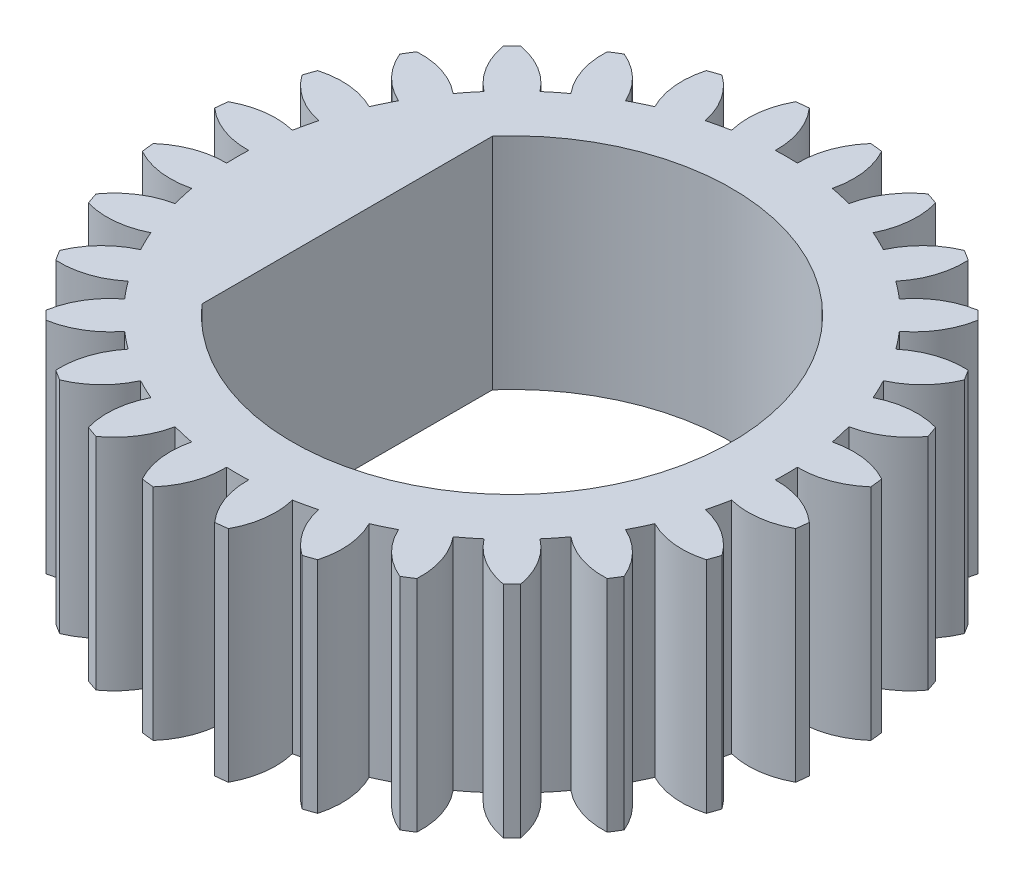
from build123d import *

# Parameters (mm, degrees)
BOSS_EXTRUDE1_DEPTH = 1
SCALE1_SCALE        = 2


with BuildPart() as part:
    # Sketch1 → Boss-Extrude1 (new body)
    with BuildSketch(Plane(origin=(0, 0, 0), x_dir=(1, 0, 0), z_dir=(0, 1, 0))):
        with BuildLine():
            ThreePointArc((0.19583451, 1.487161338), (0.167946714, 1.490568315), (0.14, 1.493452376))
            ThreePointArc((0.14, 1.493452376), (0.071938149, 1.379716653), (0.05, 1.2489996))
            ThreePointArc((0.05, 1.2489996), (0, 1.25), (-0.05, 1.2489996))
            ThreePointArc((-0.05, 1.2489996), (-0.071938149, 1.379716653), (-0.14, 1.493452376))
            ThreePointArc((-0.14, 1.493452376), (-0.167946714, 1.490568315), (-0.19583451, 1.487161338))
            ThreePointArc((-0.19583451, 1.487161338), (-0.236881329, 1.36113202), (-0.229182162, 1.228810619))
            ThreePointArc((-0.229182162, 1.228810619), (-0.278151167, 1.21865989), (-0.326674953, 1.206558525))
            ThreePointArc((-0.326674953, 1.206558525), (-0.377150347, 1.329116532), (-0.468814325, 1.424855476))
            ThreePointArc((-0.468814325, 1.424855476), (-0.495418593, 1.415824995), (-0.52184906, 1.40629782))
            ThreePointArc((-0.52184906, 1.40629782), (-0.533822588, 1.274294544), (-0.496872173, 1.147003942))
            ThreePointArc((-0.496872173, 1.147003942), (-0.542354674, 1.126211085), (-0.58696906, 1.103615568))
            ThreePointArc((-0.58696906, 1.103615568), (-0.663450653, 1.211868958), (-0.774120343, 1.284810373))
            ThreePointArc((-0.774120343, 1.284810373), (-0.798048115, 1.270086299), (-0.821695919, 1.254916658))
            ThreePointArc((-0.821695919, 1.254916658), (-0.803995753, 1.123558618), (-0.739646939, 1.007681699))
            ThreePointArc((-0.739646939, 1.007681699), (-0.779362252, 0.977289353), (-0.817830087, 0.945332719))
            ThreePointArc((-0.817830087, 0.945332719), (-0.916482772, 1.033853214), (-1.040608734, 1.080339513))
            ThreePointArc((-1.040608734, 1.080339513), (-1.060660172, 1.060660172), (-1.080339513, 1.040608734))
            ThreePointArc((-1.080339513, 1.040608734), (-1.033853214, 0.916482772), (-0.945332719, 0.817830087))
            ThreePointArc((-0.945332719, 0.817830087), (-0.977289353, 0.779362252), (-1.007681699, 0.739646939))
            ThreePointArc((-1.007681699, 0.739646939), (-1.123558618, 0.803995753), (-1.254916658, 0.821695919))
            ThreePointArc((-1.254916658, 0.821695919), (-1.270086299, 0.798048115), (-1.284810373, 0.774120343))
            ThreePointArc((-1.284810373, 0.774120343), (-1.211868958, 0.663450653), (-1.103615568, 0.58696906))
            ThreePointArc((-1.103615568, 0.58696906), (-1.126211085, 0.542354674), (-1.147003942, 0.496872173))
            ThreePointArc((-1.147003942, 0.496872173), (-1.274294544, 0.533822588), (-1.40629782, 0.52184906))
            ThreePointArc((-1.40629782, 0.52184906), (-1.415824995, 0.495418593), (-1.424855476, 0.468814325))
            ThreePointArc((-1.424855476, 0.468814325), (-1.329116532, 0.377150347), (-1.206558525, 0.326674953))
            ThreePointArc((-1.206558525, 0.326674953), (-1.21865989, 0.278151167), (-1.228810619, 0.229182162))
            ThreePointArc((-1.228810619, 0.229182162), (-1.36113202, 0.236881329), (-1.487161338, 0.19583451))
            ThreePointArc((-1.487161338, 0.19583451), (-1.490568315, 0.167946714), (-1.493452376, 0.14))
            ThreePointArc((-1.493452376, 0.14), (-1.379716653, 0.071938149), (-1.2489996, 0.05))
            ThreePointArc((-1.2489996, 0.05), (-1.25, 0), (-1.2489996, -0.05))
            ThreePointArc((-1.2489996, -0.05), (-1.379716653, -0.071938149), (-1.493452376, -0.14))
            ThreePointArc((-1.493452376, -0.14), (-1.490568315, -0.167946714), (-1.487161338, -0.19583451))
            ThreePointArc((-1.487161338, -0.19583451), (-1.36113202, -0.236881329), (-1.228810619, -0.229182162))
            ThreePointArc((-1.228810619, -0.229182162), (-1.21865989, -0.278151167), (-1.206558525, -0.326674953))
            ThreePointArc((-1.206558525, -0.326674953), (-1.329116532, -0.377150347), (-1.424855476, -0.468814325))
            ThreePointArc((-1.424855476, -0.468814325), (-1.415824995, -0.495418593), (-1.40629782, -0.52184906))
            ThreePointArc((-1.40629782, -0.52184906), (-1.274294544, -0.533822588), (-1.147003942, -0.496872173))
            ThreePointArc((-1.147003942, -0.496872173), (-1.126211085, -0.542354674), (-1.103615568, -0.58696906))
            ThreePointArc((-1.103615568, -0.58696906), (-1.211868958, -0.663450653), (-1.284810373, -0.774120343))
            ThreePointArc((-1.284810373, -0.774120343), (-1.270086299, -0.798048115), (-1.254916658, -0.821695919))
            ThreePointArc((-1.254916658, -0.821695919), (-1.123558618, -0.803995753), (-1.007681699, -0.739646939))
            ThreePointArc((-1.007681699, -0.739646939), (-0.977289353, -0.779362252), (-0.945332719, -0.817830087))
            ThreePointArc((-0.945332719, -0.817830087), (-1.033853214, -0.916482772), (-1.080339513, -1.040608734))
            ThreePointArc((-1.080339513, -1.040608734), (-1.060660172, -1.060660172), (-1.040608734, -1.080339513))
            ThreePointArc((-1.040608734, -1.080339513), (-0.916482772, -1.033853214), (-0.817830087, -0.945332719))
            ThreePointArc((-0.817830087, -0.945332719), (-0.779362252, -0.977289353), (-0.739646939, -1.007681699))
            ThreePointArc((-0.739646939, -1.007681699), (-0.803995753, -1.123558618), (-0.821695919, -1.254916658))
            ThreePointArc((-0.821695919, -1.254916658), (-0.798048115, -1.270086299), (-0.774120343, -1.284810373))
            ThreePointArc((-0.774120343, -1.284810373), (-0.663450653, -1.211868958), (-0.58696906, -1.103615568))
            ThreePointArc((-0.58696906, -1.103615568), (-0.542354674, -1.126211085), (-0.496872173, -1.147003942))
            ThreePointArc((-0.496872173, -1.147003942), (-0.533822588, -1.274294544), (-0.52184906, -1.40629782))
            ThreePointArc((-0.52184906, -1.40629782), (-0.495418593, -1.415824995), (-0.468814325, -1.424855476))
            ThreePointArc((-0.468814325, -1.424855476), (-0.377150347, -1.329116532), (-0.326674953, -1.206558525))
            ThreePointArc((-0.326674953, -1.206558525), (-0.278151167, -1.21865989), (-0.229182162, -1.228810619))
            ThreePointArc((-0.229182162, -1.228810619), (-0.236881329, -1.36113202), (-0.19583451, -1.487161338))
            ThreePointArc((-0.19583451, -1.487161338), (-0.167946714, -1.490568315), (-0.14, -1.493452376))
            ThreePointArc((-0.14, -1.493452376), (-0.071938149, -1.379716653), (-0.05, -1.2489996))
            ThreePointArc((-0.05, -1.2489996), (0, -1.25), (0.05, -1.2489996))
            ThreePointArc((0.05, -1.2489996), (0.071938149, -1.379716653), (0.14, -1.493452376))
            ThreePointArc((0.14, -1.493452376), (0.167946714, -1.490568315), (0.19583451, -1.487161338))
            ThreePointArc((0.19583451, -1.487161338), (0.236881329, -1.36113202), (0.229182162, -1.228810619))
            ThreePointArc((0.229182162, -1.228810619), (0.278151167, -1.21865989), (0.326674953, -1.206558525))
            ThreePointArc((0.326674953, -1.206558525), (0.377150347, -1.329116532), (0.468814325, -1.424855476))
            ThreePointArc((0.468814325, -1.424855476), (0.495418593, -1.415824995), (0.52184906, -1.40629782))
            ThreePointArc((0.52184906, -1.40629782), (0.533822588, -1.274294544), (0.496872173, -1.147003942))
            ThreePointArc((0.496872173, -1.147003942), (0.542354674, -1.126211085), (0.58696906, -1.103615568))
            ThreePointArc((0.58696906, -1.103615568), (0.663450653, -1.211868958), (0.774120343, -1.284810373))
            ThreePointArc((0.774120343, -1.284810373), (0.798048115, -1.270086299), (0.821695919, -1.254916658))
            ThreePointArc((0.821695919, -1.254916658), (0.803995753, -1.123558618), (0.739646939, -1.007681699))
            ThreePointArc((0.739646939, -1.007681699), (0.779362252, -0.977289353), (0.817830087, -0.945332719))
            ThreePointArc((0.817830087, -0.945332719), (0.916482772, -1.033853214), (1.040608734, -1.080339513))
            ThreePointArc((1.040608734, -1.080339513), (1.060660172, -1.060660172), (1.080339513, -1.040608734))
            ThreePointArc((1.080339513, -1.040608734), (1.033853214, -0.916482772), (0.945332719, -0.817830087))
            ThreePointArc((0.945332719, -0.817830087), (0.977289353, -0.779362252), (1.007681699, -0.739646939))
            ThreePointArc((1.007681699, -0.739646939), (1.123558618, -0.803995753), (1.254916658, -0.821695919))
            ThreePointArc((1.254916658, -0.821695919), (1.270086299, -0.798048115), (1.284810373, -0.774120343))
            ThreePointArc((1.284810373, -0.774120343), (1.211868958, -0.663450653), (1.103615568, -0.58696906))
            ThreePointArc((1.103615568, -0.58696906), (1.126211085, -0.542354674), (1.147003942, -0.496872173))
            ThreePointArc((1.147003942, -0.496872173), (1.274294544, -0.533822588), (1.40629782, -0.52184906))
            ThreePointArc((1.40629782, -0.52184906), (1.415824995, -0.495418593), (1.424855476, -0.468814325))
            ThreePointArc((1.424855476, -0.468814325), (1.329116532, -0.377150347), (1.206558525, -0.326674953))
            ThreePointArc((1.206558525, -0.326674953), (1.21865989, -0.278151167), (1.228810619, -0.229182162))
            ThreePointArc((1.228810619, -0.229182162), (1.36113202, -0.236881329), (1.487161338, -0.19583451))
            ThreePointArc((1.487161338, -0.19583451), (1.490568315, -0.167946714), (1.493452376, -0.14))
            ThreePointArc((1.493452376, -0.14), (1.379716653, -0.071938149), (1.2489996, -0.05))
            ThreePointArc((1.2489996, -0.05), (1.25, 0), (1.2489996, 0.05))
            ThreePointArc((1.2489996, 0.05), (1.379716653, 0.071938149), (1.493452376, 0.14))
            ThreePointArc((1.493452376, 0.14), (1.490568315, 0.167946714), (1.487161338, 0.19583451))
            ThreePointArc((1.487161338, 0.19583451), (1.36113202, 0.236881329), (1.228810619, 0.229182162))
            ThreePointArc((1.228810619, 0.229182162), (1.21865989, 0.278151167), (1.206558525, 0.326674953))
            ThreePointArc((1.206558525, 0.326674953), (1.329116532, 0.377150347), (1.424855476, 0.468814325))
            ThreePointArc((1.424855476, 0.468814325), (1.415824995, 0.495418593), (1.40629782, 0.52184906))
            ThreePointArc((1.40629782, 0.52184906), (1.274294544, 0.533822588), (1.147003942, 0.496872173))
            ThreePointArc((1.147003942, 0.496872173), (1.126211085, 0.542354674), (1.103615568, 0.58696906))
            ThreePointArc((1.103615568, 0.58696906), (1.211868958, 0.663450653), (1.284810373, 0.774120343))
            ThreePointArc((1.284810373, 0.774120343), (1.270086299, 0.798048115), (1.254916658, 0.821695919))
            ThreePointArc((1.254916658, 0.821695919), (1.123558618, 0.803995753), (1.007681699, 0.739646939))
            ThreePointArc((1.007681699, 0.739646939), (0.977289353, 0.779362252), (0.945332719, 0.817830087))
            ThreePointArc((0.945332719, 0.817830087), (1.033853214, 0.916482772), (1.080339513, 1.040608734))
            ThreePointArc((1.080339513, 1.040608734), (1.060660172, 1.060660172), (1.040608734, 1.080339513))
            ThreePointArc((1.040608734, 1.080339513), (0.916482772, 1.033853214), (0.817830087, 0.945332719))
            ThreePointArc((0.817830087, 0.945332719), (0.779362252, 0.977289353), (0.739646939, 1.007681699))
            ThreePointArc((0.739646939, 1.007681699), (0.803995753, 1.123558618), (0.821695919, 1.254916658))
            ThreePointArc((0.821695919, 1.254916658), (0.798048115, 1.270086299), (0.774120343, 1.284810373))
            ThreePointArc((0.774120343, 1.284810373), (0.663450653, 1.211868958), (0.58696906, 1.103615568))
            ThreePointArc((0.58696906, 1.103615568), (0.542354674, 1.126211085), (0.496872173, 1.147003942))
            ThreePointArc((0.496872173, 1.147003942), (0.533822588, 1.274294544), (0.52184906, 1.40629782))
            ThreePointArc((0.52184906, 1.40629782), (0.495418593, 1.415824995), (0.468814325, 1.424855476))
            ThreePointArc((0.468814325, 1.424855476), (0.377150347, 1.329116532), (0.326674953, 1.206558525))
            ThreePointArc((0.326674953, 1.206558525), (0.278151167, 1.21865989), (0.229182162, 1.228810619))
            ThreePointArc((0.229182162, 1.228810619), (0.236881329, 1.36113202), (0.19583451, 1.487161338))
        make_face()
        with BuildLine():
            Line((-0.75, 0), (-0.75, 0.661437828))
            ThreePointArc((-0.75, 0.661437828), (1, 0), (-0.75, -0.661437828))
            Line((-0.75, -0.661437828), (-0.75, 0))
        make_face(mode=Mode.SUBTRACT)
    extrude(amount=BOSS_EXTRUDE1_DEPTH)


with BuildPart() as part_1:
    # Scale1: scaled about (0, 0, 0)
    add(part.part.scale(SCALE1_SCALE))


solid = part_1.part
